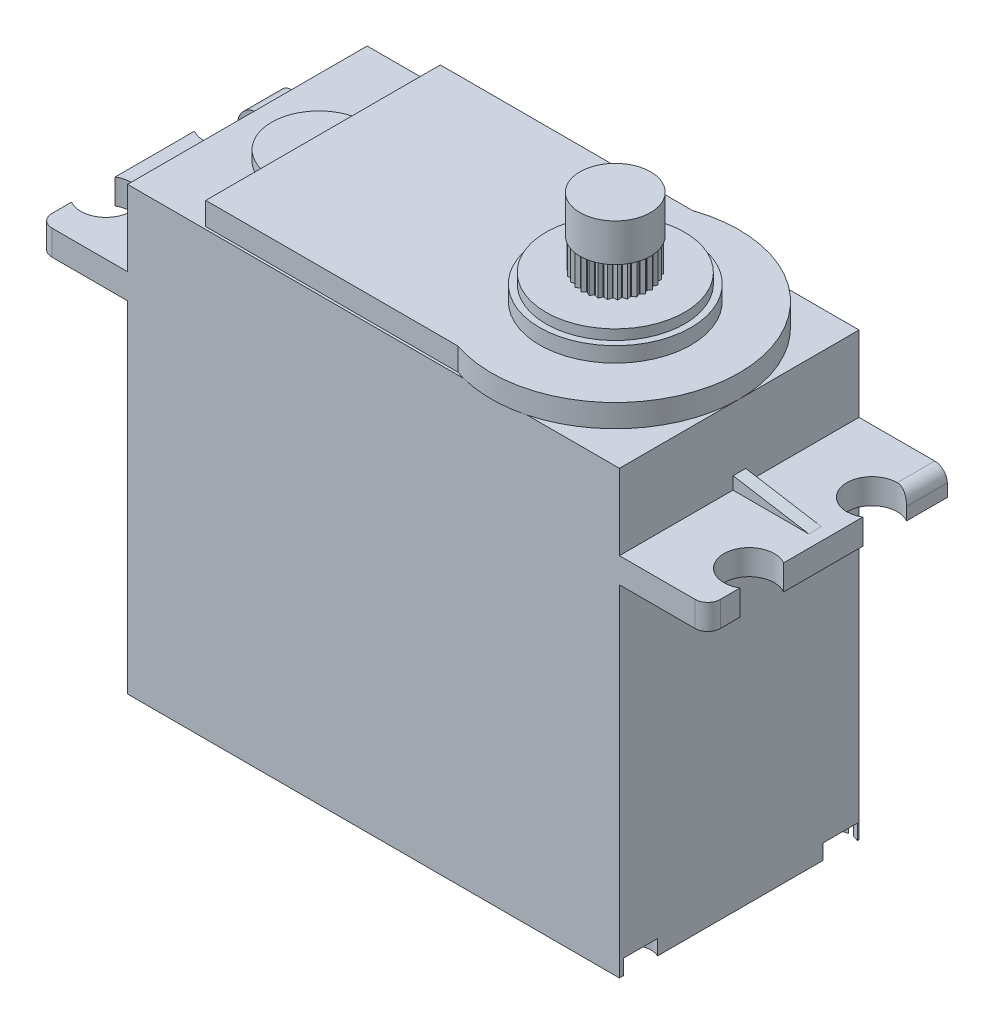
from build123d import *

# Parameters (mm, degrees)
SKETCH1_W            = 39
SKETCH1_H            = 35
BOSS_EXTRUDE1_DEPTH  = 19
SKETCH2_W            = 7
SKETCH2_H            = 2
BOSS_EXTRUDE2_DEPTH  = 19
BOSS_EXTRUDE3_DEPTH  = 0.5
SKETCH4_R            = 2
CUT_EXTRUDE1_DEPTH   = 3
FILLET1_R            = 1
BOSS_EXTRUDE4_DEPTH  = 1.8
SKETCH6_R            = 1.5
CUT_EXTRUDE2_DEPTH   = 1.2
SKETCH7_R            = 6
BOSS_EXTRUDE5_DEPTH  = 1.2
SKETCH8_R            = 5.5
BOSS_EXTRUDE6_DEPTH  = 0.8
BOSS_EXTRUDE7_DEPTH  = 0.8
SKETCH10_R           = 2.5
BOSS_EXTRUDE8_DEPTH  = 4
BOSS_EXTRUDE9_DEPTH  = 4
CIRPATTERN2_COUNT    = 30
SKETCH12_R           = 1.5
CUT_EXTRUDE4_DEPTH   = 4
SKETCH13_R           = 2.8
BOSS_EXTRUDE10_DEPTH = 1.5


with BuildPart() as part:
    # Sketch1 → Boss-Extrude1 (new body)
    with BuildSketch(Plane.XY):
        with Locations((-4.183412042, -9.229571984)):
            Rectangle(SKETCH1_W, SKETCH1_H)
    extrude(amount=BOSS_EXTRUDE1_DEPTH)

    # Sketch2 → Boss-Extrude2 (add)
    with BuildSketch(Plane.XY.offset(19)):
        with Locations((18.816587958, 1.270428016)):
            Rectangle(SKETCH2_W, SKETCH2_H)
        with Locations((-27.183412042, 1.270428016)):
            Rectangle(SKETCH2_W, SKETCH2_H)
    extrude(amount=-BOSS_EXTRUDE2_DEPTH)

    # Sketch3 → Boss-Extrude3 (add, symmetric)
    with BuildSketch(Plane.XY.offset(9.5)):
        Polygon((15.333582704, 3.272295291), (15.333582704, 2.272295291), (21.333582704, 2.272295291), align=None)
        Polygon((-29.666485395, 2.272295291), (-23.666485395, 3.272295291), (-23.666485395, 2.272295291), align=None)
    extrude(amount=BOSS_EXTRUDE3_DEPTH, both=True)

    # Sketch4 → Cut-Extrude1 (cut)
    with BuildSketch(Plane(origin=(0, 2.270428016, 0), x_dir=(1, 0, 0), z_dir=(0, 1, 0))):
        with Locations((21.316587958, -14.710690781)):
            Circle(SKETCH4_R)
        with Locations((21.316587958, -4.967002747)):
            Circle(SKETCH4_R)
        with Locations((-29.683412042, -14.710690781)):
            Circle(SKETCH4_R)
        with Locations((-29.683412042, -4.967002747)):
            Circle(SKETCH4_R)
    extrude(amount=-CUT_EXTRUDE1_DEPTH, mode=Mode.SUBTRACT)

    # Fillet1
    fillet1_edges = [part.edges().sort_by_distance(p)[0] for p in [
        (-30.683412042, 1.270428016, 19),
        (-30.683412042, 2.270428016, 1.61747597),
        (22.316587958, 2.270428016, 1.61747597),
        (22.316587958, 1.270428016, 19),
    ]]
    fillet(fillet1_edges, radius=FILLET1_R)

    # Sketch5 → Boss-Extrude4 (add)
    with BuildSketch(Plane(origin=(0, 8.270428016, 0), x_dir=(1, 0, 0), z_dir=(0, 1, 0))):
        with BuildLine():
            Line((-17.683412042, -0.2), (-17.683412042, -18.8))
            Line((-17.683412042, -18.8), (2.316587958, -18.8))
            ThreePointArc((2.316587958, -18.8), (15.316587958, -9.5), (2.316587958, -0.2))
            Line((2.316587958, -0.2), (-17.683412042, -0.2))
        make_face()
    extrude(amount=BOSS_EXTRUDE4_DEPTH)

    # Sketch6 → Cut-Extrude2 (cut)
    with BuildSketch(Plane.XZ.offset(26.729571984)):
        with Locations((-22.660585011, 17.329722527)):
            Circle(SKETCH6_R)
        with Locations((-22.660585011, 1.487126069)):
            Circle(SKETCH6_R)
        with Locations((14.670467636, 17.329722527)):
            Circle(SKETCH6_R)
        with Locations((14.670467636, 1.487126069)):
            Circle(SKETCH6_R)
    extrude(amount=-CUT_EXTRUDE2_DEPTH, mode=Mode.SUBTRACT)

    # Sketch7 → Boss-Extrude5 (add)
    with BuildSketch(Plane(origin=(0, 10.070428016, 0), x_dir=(1, 0, 0), z_dir=(0, 1, 0))):
        with Locations((5.490049496, -9.5)):
            Circle(SKETCH7_R)
    extrude(amount=BOSS_EXTRUDE5_DEPTH)

    # Sketch8 → Boss-Extrude6 (add)
    with BuildSketch(Plane(origin=(0, 11.270428016, 0), x_dir=(1, 0, 0), z_dir=(0, 1, 0))):
        with Locations((5.490049496, -9.5)):
            Circle(SKETCH8_R)
    extrude(amount=BOSS_EXTRUDE6_DEPTH)

    # Sketch9 → Boss-Extrude7 (add)
    with BuildSketch(Plane(origin=(0, 8.270428016, 0), x_dir=(1, 0, 0), z_dir=(0, 1, 0))):
        with BuildLine():
            Line((-17.683412042, -6.065911172), (-17.683412042, -13.575118742))
            ThreePointArc((-17.683412042, -13.575118742), (-21.438015827, -9.820514957), (-17.683412042, -6.065911172))
        make_face()
    extrude(amount=BOSS_EXTRUDE7_DEPTH)

    # Sketch10 → Boss-Extrude8 (add)
    with BuildSketch(Plane(origin=(0, 12.070428016, 0), x_dir=(1, 0, 0), z_dir=(0, 1, 0))):
        with Locations((5.490049496, -9.5)):
            Circle(SKETCH10_R)
    extrude(amount=BOSS_EXTRUDE8_DEPTH)

    # Sketch11 → Boss-Extrude9 (add)
    with BuildSketch(Plane(origin=(0, 16.070428016, 0), x_dir=(1, 0, 0), z_dir=(0, 1, 0))):
        Polygon((5.503448723, -6.801928291), (5.263137454, -7.010319112), (5.736737319, -7.012200748), align=None)
    boss_extrude9 = extrude(amount=-BOSS_EXTRUDE9_DEPTH)

    # CirPattern2: Boss-Extrude9 ×30 about axis
    cirpattern2_axis = Axis((5.490049496, 0, 9.5), (0, 1, 0))
    for i in range(1, CIRPATTERN2_COUNT):
        add(boss_extrude9.rotate(cirpattern2_axis, i * 360 / CIRPATTERN2_COUNT))

    # Sketch12 → Cut-Extrude4 (cut)
    with BuildSketch(Plane(origin=(0, 16.070428016, 0), x_dir=(1, 0, 0), z_dir=(0, 1, 0))):
        with Locations((5.490049496, -9.5)):
            Circle(SKETCH12_R)
    extrude(amount=-CUT_EXTRUDE4_DEPTH, mode=Mode.SUBTRACT)

    # Sketch13 → Boss-Extrude10 (add, symmetric)
    with BuildSketch(Plane(origin=(0, 16.070428016, 0), x_dir=(1, 0, 0), z_dir=(0, 1, 0))):
        with Locations((5.490049496, -9.5)):
            Circle(SKETCH13_R)
    extrude(amount=BOSS_EXTRUDE10_DEPTH, both=True)


solid = part.part
